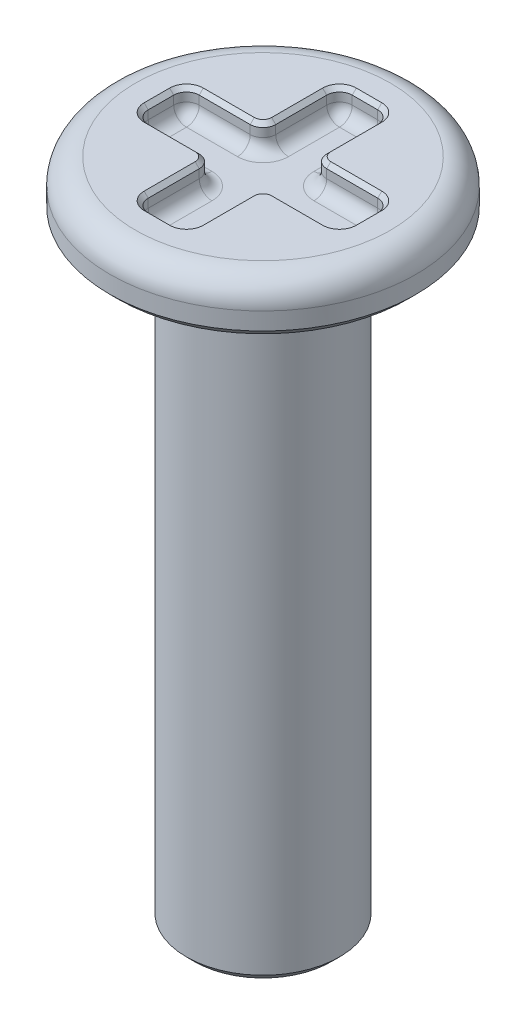
from build123d import *

# Parameters (mm, degrees)
CUT_EXTRUDE1_DEPTH = 0.79375
FILLET2_R          = 0.79375
FILLET3_R          = 0.396875
CHAMFER1_SIZE      = 0.254
CHAMFER2_SIZE      = 0.127


with BuildPart() as part:
    # Sketch1 → Revolve1 (revolve)
    with BuildSketch(Plane.XY):
        Polygon((0, 0), (2.38125, 0), (2.38125, 19.05), (4.7625, 19.05), (4.7625, 20.6375), (0, 20.6375), align=None)
    revolve(axis=Axis((0, 5.173549107, 0), (0, -1, 0)))

    # Sketch2 → Cut-Extrude1 (cut)
    with BuildSketch(Plane(origin=(0, 20.6375, 0), x_dir=(1, 0, 0), z_dir=(0, 1, 0))):
        Polygon((-3.175, 0.79375), (-0.79375, 0.79375), (-0.79375, 3.175), (0.79375, 3.175), (0.79375, 0.79375), (3.175, 0.79375), (3.175, -0.79375), (0.79375, -0.79375), (0.79375, -3.175), (-0.79375, -3.175), (-0.79375, -0.79375), (-3.175, -0.79375), align=None)
    extrude(amount=-CUT_EXTRUDE1_DEPTH, mode=Mode.SUBTRACT)

    # Fillet2
    fillet2_edges = [part.edges().sort_by_distance(p)[0] for p in [
        (-4.7625, 20.6375, 0),
        (-2.38125, 19.05, 0),
    ]]
    fillet(fillet2_edges, radius=FILLET2_R)

    # Fillet3
    fillet3_edges = [part.edges().sort_by_distance(p)[0] for p in [
        (-3.175, 20.240625, -0.79375),
        (-0.79375, 20.240625, -0.79375),
        (-0.79375, 20.240625, -3.175),
        (0.79375, 20.240625, -3.175),
        (0.79375, 20.240625, -0.79375),
        (3.175, 20.240625, -0.79375),
        (3.175, 20.240625, 0.79375),
        (0.79375, 20.240625, 0.79375),
        (0.79375, 20.240625, 3.175),
        (-0.79375, 20.240625, 3.175),
        (-0.79375, 20.240625, 0.79375),
        (-3.175, 20.240625, 0.79375),
        (-1.984375, 19.84375, -0.79375),
        (-0.79375, 19.84375, -1.984375),
        (0, 19.84375, -3.175),
        (0.79375, 19.84375, -1.984375),
        (1.984375, 19.84375, -0.79375),
        (3.175, 19.84375, 0),
        (1.984375, 19.84375, 0.79375),
        (0.79375, 19.84375, 1.984375),
        (0, 19.84375, 3.175),
        (-0.79375, 19.84375, 1.984375),
        (-1.984375, 19.84375, 0.79375),
        (-3.175, 19.84375, 0),
    ]]
    fillet(fillet3_edges, radius=FILLET3_R)

    # Chamfer1
    chamfer1_edges = [part.edges().sort_by_distance(p)[0] for p in [
        (-4.7625, 19.05, 0),
        (-2.38125, 0, 0),
    ]]
    chamfer(chamfer1_edges, length=CHAMFER1_SIZE)

    # Chamfer2
    chamfer2_edges = [part.edges().sort_by_distance(p)[0] for p in [
        (-1.984375, 20.6375, -0.79375),
        (-0.79375, 20.6375, -1.984375),
        (0, 20.6375, -3.175),
        (0.79375, 20.6375, -1.984375),
        (1.984375, 20.6375, -0.79375),
        (3.175, 20.6375, 0),
        (1.984375, 20.6375, 0.79375),
        (0.79375, 20.6375, 1.984375),
        (0, 20.6375, 3.175),
        (-0.79375, 20.6375, 1.984375),
        (-1.984375, 20.6375, 0.79375),
        (-3.175, 20.6375, 0),
        (-0.909991996, 20.6375, -0.909991996),
        (0.909991996, 20.6375, -0.909991996),
        (0.909991996, 20.6375, 0.909991996),
        (-0.909991996, 20.6375, 0.909991996),
        (-3.058758004, 20.6375, -0.677508004),
        (-3.058758004, 20.6375, 0.677508004),
        (-0.677508004, 20.6375, 3.058758004),
        (0.677508004, 20.6375, 3.058758004),
        (3.058758004, 20.6375, 0.677508004),
        (3.058758004, 20.6375, -0.677508004),
        (-0.677508004, 20.6375, -3.058758004),
        (0.677508004, 20.6375, -3.058758004),
    ]]
    chamfer(chamfer2_edges, length=CHAMFER2_SIZE)


solid = part.part
